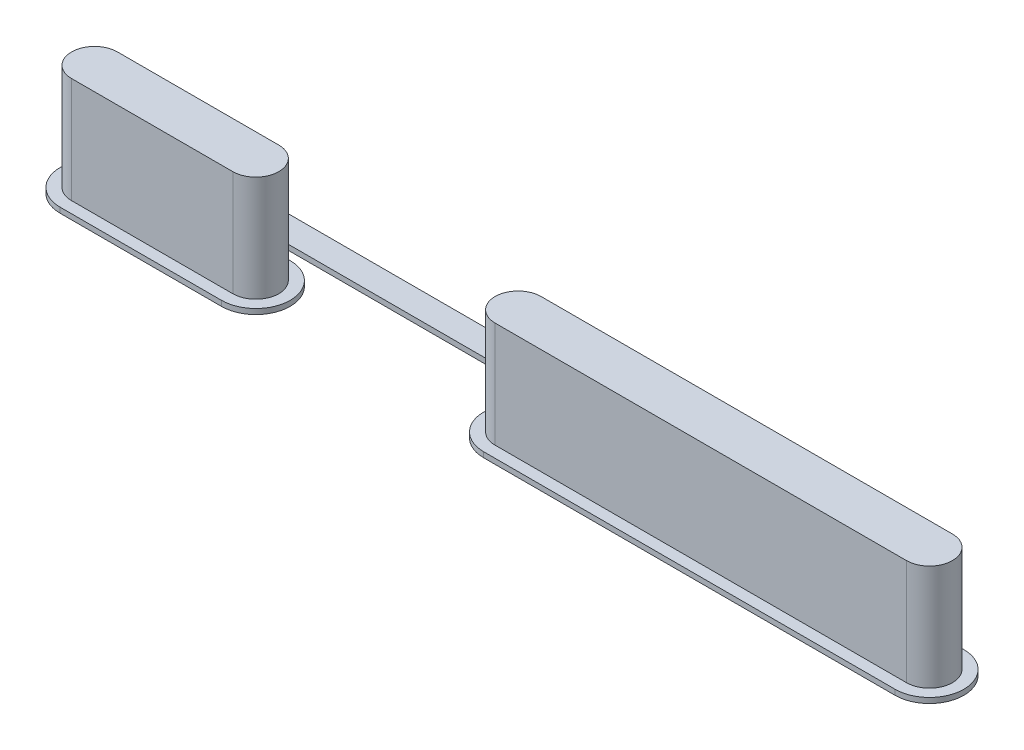
from build123d import *

# Parameters (mm, degrees)
BOSS_EXTRUDE1_DEPTH   = 5.08
BOSS_EXTRUDE1_2_DEPTH = 5.08
BOSS_EXTRUDE2_DEPTH   = 0.254
EXTRUDE_THIN1_DEPTH   = 0.254
FILLET1_R             = 0.254


with BuildPart() as part:
    # Sketch1 → Boss-Extrude1 (new body)
    with BuildSketch(Plane(origin=(0, 0, 0), x_dir=(1, 0, 0), z_dir=(0, 1, 0))):
        with BuildLine():
            Line((-3.8735, 1.1049), (3.8735, 1.1049))
            ThreePointArc((3.8735, 1.1049), (4.9784, 0), (3.8735, -1.1049))
            Line((3.8735, -1.1049), (-3.8735, -1.1049))
            ThreePointArc((-3.8735, -1.1049), (-4.9784, 0), (-3.8735, 1.1049))
        make_face()
    extrude(amount=BOSS_EXTRUDE1_DEPTH)

    # Sketch3 → Boss-Extrude2 (add)
    with BuildSketch(Plane(origin=(0, 0, 0), x_dir=(1, 0, 0), z_dir=(0, 1, 0))):
        with BuildLine():
            Line((-3.8735, 1.651), (3.8735, 1.651))
            ThreePointArc((3.8735, 1.651), (5.5245, 0), (3.8735, -1.651))
            Line((3.8735, -1.651), (-3.8735, -1.651))
            ThreePointArc((-3.8735, -1.651), (-5.5245, 0), (-3.8735, 1.651))
        make_face()
        with BuildLine():
            Line((16.4719, 1.651), (36.2331, 1.651))
            ThreePointArc((36.2331, 1.651), (37.8841, 0), (36.2331, -1.651))
            Line((36.2331, -1.651), (16.4719, -1.651))
            ThreePointArc((16.4719, -1.651), (14.8209, 0), (16.4719, 1.651))
        make_face()
    extrude(amount=-BOSS_EXTRUDE2_DEPTH)

    # Sketch4 → Extrude-Thin1 (add)
    with BuildSketch(Plane(origin=(0, 0, 0), x_dir=(1, 0, 0), z_dir=(0, 1, 0))):
        with BuildLine():
            Line((0.635, 1.651), (0.635, 2.032))
            ThreePointArc((0.635, 2.032), (0.709394878, 2.211605122), (0.889, 2.286))
            Line((0.889, 2.286), (25.4635, 2.286))
            ThreePointArc((25.4635, 2.286), (25.643105122, 2.211605122), (25.7175, 2.032))
            Line((25.7175, 2.032), (25.7175, 1.651))
            Line((25.7175, 1.651), (26.9875, 1.651))
            Line((26.9875, 1.651), (26.9875, 2.032))
            ThreePointArc((26.9875, 2.032), (26.541130735, 3.109630735), (25.4635, 3.556))
            Line((25.4635, 3.556), (0.889, 3.556))
            ThreePointArc((0.889, 3.556), (-0.188630735, 3.109630735), (-0.635, 2.032))
            Line((-0.635, 2.032), (-0.635, 1.651))
            Line((-0.635, 1.651), (0.635, 1.651))
        make_face()
    extrude(amount=-EXTRUDE_THIN1_DEPTH)

    # Fillet1
    fillet1_edges = [part.edges().sort_by_distance(p)[0] for p in [
        (26.9875, -0.127, -1.651),
        (-0.635, -0.127, -1.651),
        (0.635, -0.127, -1.651),
        (25.7175, -0.127, -1.651),
    ]]
    fillet(fillet1_edges, radius=FILLET1_R)


with BuildPart() as body_2:
    # Sketch1 → Boss-Extrude1 2 (new body)
    with BuildSketch(Plane(origin=(0, 0, 0), x_dir=(1, 0, 0), z_dir=(0, 1, 0))):
        with BuildLine():
            Line((16.4719, 1.1049), (36.2331, 1.1049))
            ThreePointArc((36.2331, 1.1049), (37.338, 0), (36.2331, -1.1049))
            Line((36.2331, -1.1049), (16.4719, -1.1049))
            ThreePointArc((16.4719, -1.1049), (15.367, 0), (16.4719, 1.1049))
        make_face()
    extrude(amount=BOSS_EXTRUDE1_2_DEPTH)


solid = Compound([part.part, body_2.part])
